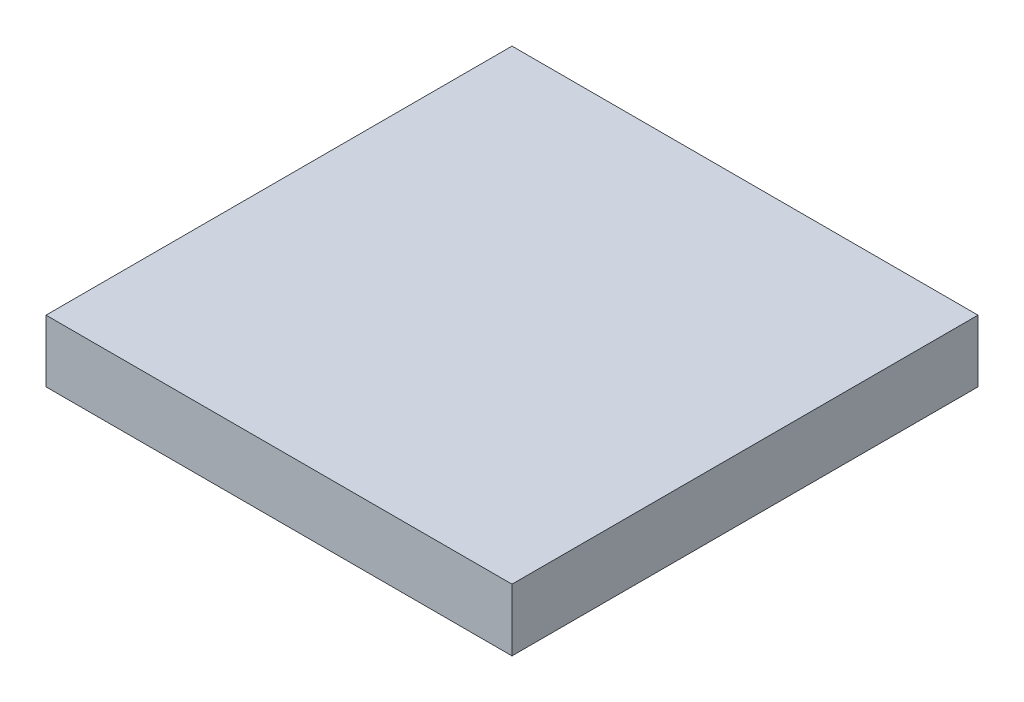
from build123d import *

# Parameters (mm, degrees)
SKETCH1_W           = 3
SKETCH1_H           = 3
BOSS_EXTRUDE1_DEPTH = 0.4


with BuildPart() as part:
    # Sketch1 → Boss-Extrude1 (new body)
    with BuildSketch(Plane(origin=(0, 0, 0), x_dir=(1, 0, 0), z_dir=(0, 1, 0))):
        Rectangle(SKETCH1_W, SKETCH1_H)
    extrude(amount=BOSS_EXTRUDE1_DEPTH)


solid = part.part
